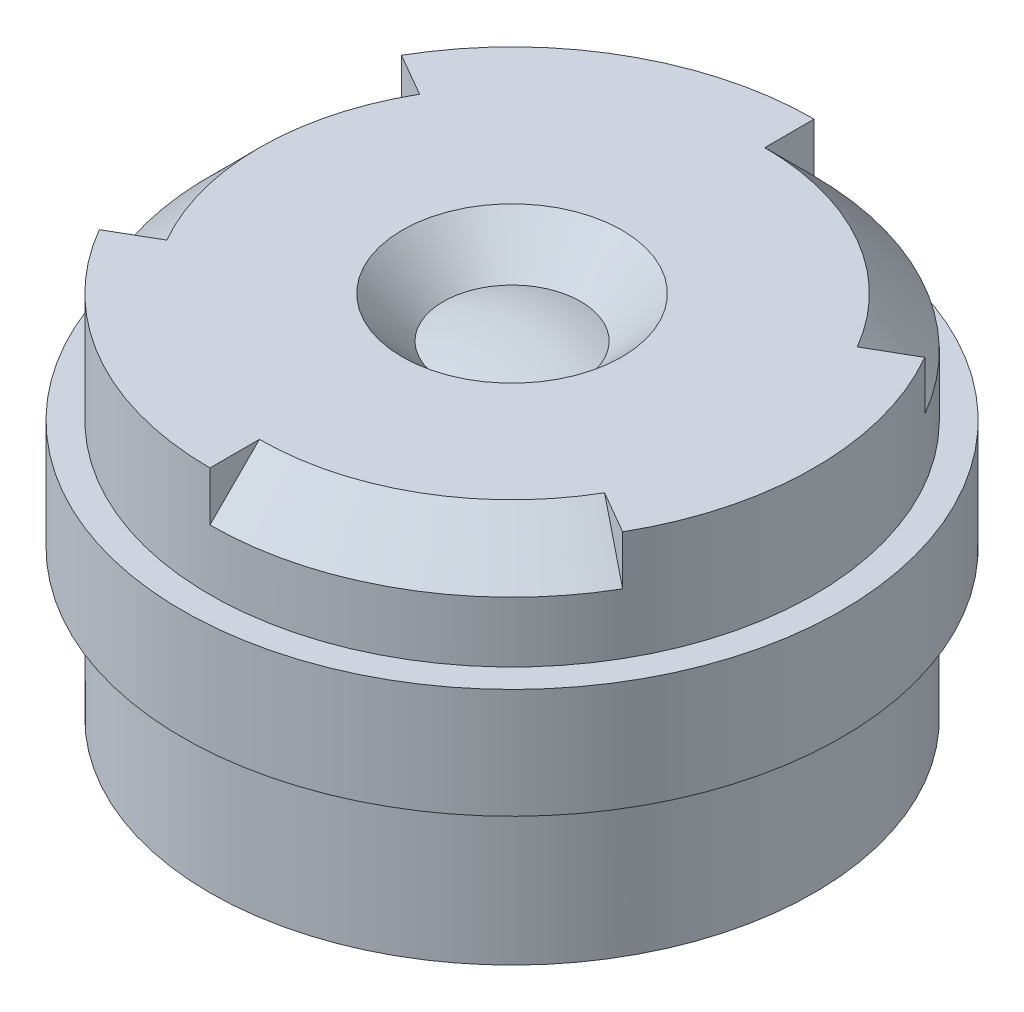
from build123d import *

# Parameters (mm, degrees)
SKIZZE4_W          = 0.25
SKIZZE4_H          = 1
TOOLFACE_ANGLE     = 60
KREISMUSTER1_COUNT = 3


with BuildPart() as part:
    # Skizze3 → Body (revolve)
    with BuildSketch(Plane.XY, mode=Mode.PRIVATE) as body_sk:
        with BuildLine():
            Line((1, 0.8), (2.75, 0.8))
            Line((2.75, 0.8), (2.75, -2.55))
            Line((2.75, -2.55), (2.1, -2.55))
            Line((2.1, -2.55), (1.8, -2.25))
            ThreePointArc((1.8, -2.25), (0.91241438, -2.474486277), (0, -2.55))
            Line((0, -2.55), (0, 0.525))
            ThreePointArc((0, 0.525), (0.316474723, 0.499842016), (0.625, 0.425))
            Line((0.625, 0.425), (1, 0.8))
        make_face()
    revolve(body_sk.sketch.rotate(Axis((0, 0, 0), (0, -1, 0)), 90), axis=Axis((0, 0, 0), (0, -1, 0)))  # turned: the seam where the file's is

    # Skizze4 → Thread (revolve)
    with BuildSketch(Plane.XY, mode=Mode.PRIVATE) as thread_sk:
        with Locations((2.875, -0.7)):
            Rectangle(SKIZZE4_W, SKIZZE4_H)
    revolve(thread_sk.sketch.rotate(Axis((0, 0, 0), (0, 1, 0)), 270), axis=Axis((0, 0, 0), (0, 1, 0)))  # turned: the seam where the file's is

    # Skizze5 → Toolface (revolve, cut)
    with BuildSketch(Plane(origin=(0, 0, 0), x_dir=(0, 0, -1), z_dir=(1, 0, 0))):
        Polygon((2.75, 0.8), (2.75, 0.35), (2.3, 0.8), align=None)
    toolface = revolve(axis=Axis((0, 0, 0), (0, -1, 0)), revolution_arc=TOOLFACE_ANGLE, mode=Mode.SUBTRACT)

    # Kreismuster1: Toolface ×3 about axis
    kreismuster1_axis = Axis((0, 0, 0), (0, 1, 0))
    for i in range(1, KREISMUSTER1_COUNT):
        add(toolface.rotate(kreismuster1_axis, i * 360 / KREISMUSTER1_COUNT), mode=Mode.SUBTRACT)


solid = part.part
